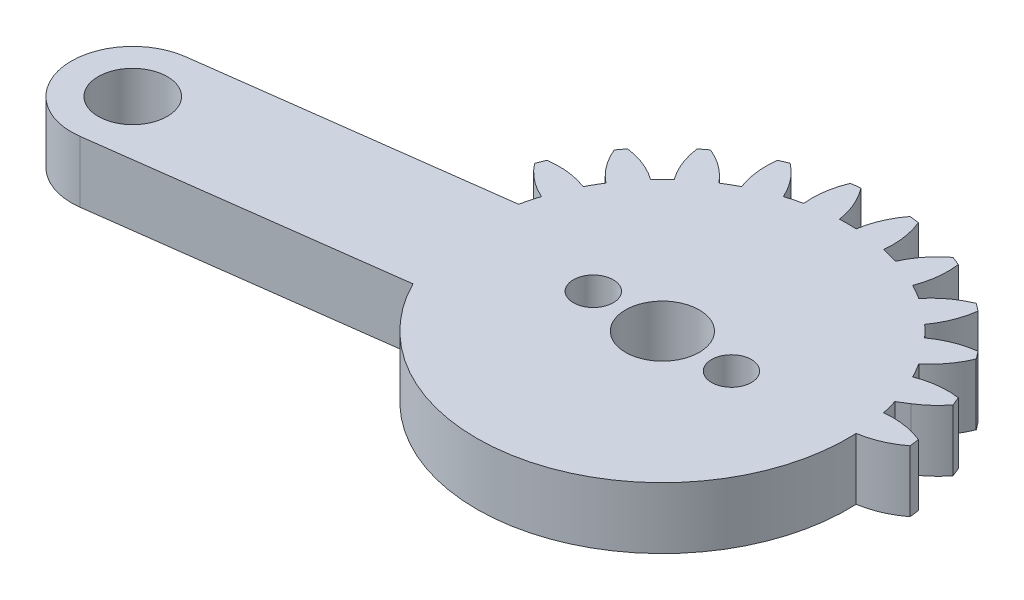
from build123d import *

# Parameters (mm, degrees)
SKETCH1_R           = 1.5
SKETCH1_R_2         = 2.25
BOSS_EXTRUDE1_DEPTH = 4
SKETCH3_R           = 2.25
BOSS_EXTRUDE2_DEPTH = 4
CUT_EXTRUDE1_DEPTH  = 4
CUT_EXTRUDE2_REACH  = 6
SKETCH5_R           = 1.3
SKETCH5_R_2         = 2.4


with BuildPart() as part:
    # Sketch1 → Boss-Extrude1 (new body)
    with BuildSketch(Plane(origin=(0, 0, 0), x_dir=(1, 0, 0), z_dir=(0, 1, 0))):
        with BuildLine():
            Line((20.643657446, 4), (2.081641936, 4))
            ThreePointArc((2.081641936, 4), (2.861028333, 4.588201733), (3.521749436, 5.30713988))
            ThreePointArc((3.521749436, 5.30713988), (3.405395609, 5.596745198), (3.282888305, 5.883801663))
            ThreePointArc((3.282888305, 5.883801663), (1.93527598, 5.894040025), (0.627094961, 5.57027124))
            ThreePointArc((0.627094961, 5.57027124), (0.366286148, 6.046375), (0.084372603, 6.510293938))
            ThreePointArc((0.084372603, 6.510293938), (1.018855105, 7.48132754), (1.683794586, 8.65351323))
            ThreePointArc((1.683794586, 8.65351323), (1.496450048, 8.903135899), (1.303821399, 9.148703928))
            ThreePointArc((1.303821399, 9.148703928), (-0.000522033, 8.809805691), (-1.180330337, 8.158486898))
            ThreePointArc((-1.180330337, 8.158486898), (-1.555477026, 8.550865528), (-1.947855656, 8.926012217))
            ThreePointArc((-1.947855656, 8.926012217), (-1.296536862, 10.105820521), (-0.957638625, 11.410163953))
            ThreePointArc((-0.957638625, 11.410163953), (-1.203206655, 11.602792602), (-1.452829324, 11.79013714))
            ThreePointArc((-1.452829324, 11.79013714), (-2.625015014, 11.125197659), (-3.596048616, 10.190715157))
            ThreePointArc((-3.596048616, 10.190715157), (-4.059967554, 10.472628702), (-4.536071314, 10.733437515))
            ThreePointArc((-4.536071314, 10.733437515), (-4.212302529, 12.041618533), (-4.222540891, 13.389230859))
            ThreePointArc((-4.222540891, 13.389230859), (-4.509597355, 13.511738163), (-4.799202674, 13.62809199))
            ThreePointArc((-4.799202674, 13.62809199), (-5.759348103, 12.682425791), (-6.455432668, 11.528463019))
            ThreePointArc((-6.455432668, 11.528463019), (-6.976508546, 11.680699536), (-7.503891752, 11.809396783))
            ThreePointArc((-7.503891752, 11.809396783), (-7.529737283, 13.156800143), (-7.888414517, 14.455843809))
            ThreePointArc((-7.888414517, 14.455843809), (-8.197396993, 14.499881098), (-8.507248835, 14.537314892))
            ThreePointArc((-8.507248835, 14.537314892), (-9.18992168, 13.375367565), (-9.563620196, 12.080565177))
            ThreePointArc((-9.563620196, 12.080565177), (-10.106342554, 12.09275), (-10.649064912, 12.080565177))
            ThreePointArc((-10.649064912, 12.080565177), (-11.022763428, 13.375367565), (-11.705436272, 14.537314892))
            ThreePointArc((-11.705436272, 14.537314892), (-12.015288115, 14.499881098), (-12.324270591, 14.455843809))
            ThreePointArc((-12.324270591, 14.455843809), (-12.682947825, 13.156800143), (-12.708793355, 11.809396783))
            ThreePointArc((-12.708793355, 11.809396783), (-13.236176561, 11.680699536), (-13.757252439, 11.528463019))
            ThreePointArc((-13.757252439, 11.528463019), (-14.453337005, 12.682425791), (-15.413482434, 13.62809199))
            ThreePointArc((-15.413482434, 13.62809199), (-15.703087752, 13.511738163), (-15.990144217, 13.389230859))
            ThreePointArc((-15.990144217, 13.389230859), (-16.000382579, 12.041618533), (-15.676613793, 10.733437515))
            ThreePointArc((-15.676613793, 10.733437515), (-16.152717554, 10.472628702), (-16.616636492, 10.190715157))
            ThreePointArc((-16.616636492, 10.190715157), (-17.587670094, 11.125197659), (-18.759855783, 11.79013714))
            ThreePointArc((-18.759855783, 11.79013714), (-19.009478453, 11.602792602), (-19.255046482, 11.410163953))
            ThreePointArc((-19.255046482, 11.410163953), (-18.916148245, 10.105820521), (-18.264829452, 8.926012217))
            ThreePointArc((-18.264829452, 8.926012217), (-18.657208082, 8.550865528), (-19.032354771, 8.158486898))
            ThreePointArc((-19.032354771, 8.158486898), (-20.212163074, 8.809805691), (-21.516506507, 9.148703928))
            ThreePointArc((-21.516506507, 9.148703928), (-21.709135156, 8.903135899), (-21.896479694, 8.65351323))
            ThreePointArc((-21.896479694, 8.65351323), (-21.231540213, 7.48132754), (-20.297057711, 6.510293938))
            ThreePointArc((-20.297057711, 6.510293938), (-20.578971255, 6.046375), (-20.839780068, 5.57027124))
            ThreePointArc((-20.839780068, 5.57027124), (-22.147961087, 5.894040025), (-23.495573413, 5.883801663))
            ThreePointArc((-23.495573413, 5.883801663), (-23.618080717, 5.596745198), (-23.734434544, 5.30713988))
            ThreePointArc((-23.734434544, 5.30713988), (-22.788768345, 4.346994451), (-21.634805572, 3.650909885))
            ThreePointArc((-21.634805572, 3.650909885), (-21.78704209, 3.129834008), (-21.915739337, 2.602450802))
            ThreePointArc((-21.915739337, 2.602450802), (-23.263142697, 2.576605271), (-24.562186363, 2.217928037))
            ThreePointArc((-24.562186363, 2.217928037), (-24.606223651, 1.908945561), (-24.643657446, 1.599093719))
            ThreePointArc((-24.643657446, 1.599093719), (-23.481710119, 0.916420874), (-22.186907731, 0.542722358))
            ThreePointArc((-22.186907731, 0.542722358), (-22.199092554, 0), (-22.186907731, -0.542722358))
            ThreePointArc((-22.186907731, -0.542722358), (-23.481710119, -0.916420874), (-24.643657446, -1.599093719))
            ThreePointArc((-24.643657446, -1.599093719), (-24.606223651, -1.908945561), (-24.562186363, -2.217928037))
            ThreePointArc((-24.562186363, -2.217928037), (-23.263142697, -2.576605271), (-21.915739337, -2.602450802))
            ThreePointArc((-21.915739337, -2.602450802), (-21.78704209, -3.129834008), (-21.634805572, -3.650909885))
            ThreePointArc((-21.634805572, -3.650909885), (-22.788768345, -4.346994451), (-23.734434544, -5.30713988))
            ThreePointArc((-23.734434544, -5.30713988), (-23.618080717, -5.596745198), (-23.495573413, -5.883801663))
            ThreePointArc((-23.495573413, -5.883801663), (-22.147961087, -5.894040025), (-20.839780068, -5.57027124))
            ThreePointArc((-20.839780068, -5.57027124), (-20.578971255, -6.046375), (-20.297057711, -6.510293938))
            ThreePointArc((-20.297057711, -6.510293938), (-21.231540213, -7.48132754), (-21.896479694, -8.65351323))
            ThreePointArc((-21.896479694, -8.65351323), (-21.709135156, -8.903135899), (-21.516506507, -9.148703928))
            ThreePointArc((-21.516506507, -9.148703928), (-20.212163074, -8.809805691), (-19.032354771, -8.158486898))
            ThreePointArc((-19.032354771, -8.158486898), (-18.657208082, -8.550865528), (-18.264829452, -8.926012217))
            ThreePointArc((-18.264829452, -8.926012217), (-18.916148245, -10.105820521), (-19.255046482, -11.410163953))
            ThreePointArc((-19.255046482, -11.410163953), (-19.009478453, -11.602792602), (-18.759855783, -11.79013714))
            ThreePointArc((-18.759855783, -11.79013714), (-17.587670094, -11.125197659), (-16.616636492, -10.190715157))
            ThreePointArc((-16.616636492, -10.190715157), (-16.152717554, -10.472628702), (-15.676613793, -10.733437515))
            ThreePointArc((-15.676613793, -10.733437515), (-16.000382579, -12.041618533), (-15.990144217, -13.389230859))
            ThreePointArc((-15.990144217, -13.389230859), (-15.703087752, -13.511738163), (-15.413482434, -13.62809199))
            ThreePointArc((-15.413482434, -13.62809199), (-14.453337005, -12.682425791), (-13.757252439, -11.528463019))
            ThreePointArc((-13.757252439, -11.528463019), (-13.236176561, -11.680699536), (-12.708793355, -11.809396783))
            ThreePointArc((-12.708793355, -11.809396783), (-12.682947825, -13.156800143), (-12.324270591, -14.455843809))
            ThreePointArc((-12.324270591, -14.455843809), (-12.015288115, -14.499881098), (-11.705436272, -14.537314892))
            ThreePointArc((-11.705436272, -14.537314892), (-11.022763428, -13.375367565), (-10.649064912, -12.080565177))
            ThreePointArc((-10.649064912, -12.080565177), (-10.106342554, -12.09275), (-9.563620196, -12.080565177))
            ThreePointArc((-9.563620196, -12.080565177), (-9.18992168, -13.375367565), (-8.507248835, -14.537314892))
            ThreePointArc((-8.507248835, -14.537314892), (-8.197396993, -14.499881098), (-7.888414517, -14.455843809))
            ThreePointArc((-7.888414517, -14.455843809), (-7.529737283, -13.156800143), (-7.503891752, -11.809396783))
            ThreePointArc((-7.503891752, -11.809396783), (-6.976508546, -11.680699536), (-6.455432668, -11.528463019))
            ThreePointArc((-6.455432668, -11.528463019), (-5.759348103, -12.682425791), (-4.799202674, -13.62809199))
            ThreePointArc((-4.799202674, -13.62809199), (-4.509597355, -13.511738163), (-4.222540891, -13.389230859))
            ThreePointArc((-4.222540891, -13.389230859), (-4.212302529, -12.041618533), (-4.536071314, -10.733437515))
            ThreePointArc((-4.536071314, -10.733437515), (-4.059967554, -10.472628702), (-3.596048616, -10.190715157))
            ThreePointArc((-3.596048616, -10.190715157), (-2.625015014, -11.125197659), (-1.452829324, -11.79013714))
            ThreePointArc((-1.452829324, -11.79013714), (-1.203206655, -11.602792602), (-0.957638625, -11.410163953))
            ThreePointArc((-0.957638625, -11.410163953), (-1.296536862, -10.105820521), (-1.947855656, -8.926012217))
            ThreePointArc((-1.947855656, -8.926012217), (-1.555477026, -8.550865528), (-1.180330337, -8.158486898))
            ThreePointArc((-1.180330337, -8.158486898), (-0.000522033, -8.809805691), (1.303821399, -9.148703928))
            ThreePointArc((1.303821399, -9.148703928), (1.496450048, -8.903135899), (1.683794586, -8.65351323))
            ThreePointArc((1.683794586, -8.65351323), (1.018855105, -7.48132754), (0.084372603, -6.510293938))
            ThreePointArc((0.084372603, -6.510293938), (0.366286148, -6.046375), (0.627094961, -5.57027124))
            ThreePointArc((0.627094961, -5.57027124), (1.93527598, -5.894040025), (3.282888305, -5.883801663))
            ThreePointArc((3.282888305, -5.883801663), (3.405395609, -5.596745198), (3.521749436, -5.30713988))
            ThreePointArc((3.521749436, -5.30713988), (2.861028333, -4.588201733), (2.081641936, -4))
            Line((2.081641936, -4), (20.643657446, -4))
            ThreePointArc((20.643657446, -4), (24.643657446, 0), (20.643657446, 4))
        make_face()
        with Locations((-10.106342554, 0)):
            Circle(SKETCH1_R, mode=Mode.SUBTRACT)
        with Locations((20.643657446, 0)):
            Circle(SKETCH1_R_2, mode=Mode.SUBTRACT)
    extrude(amount=BOSS_EXTRUDE1_DEPTH)

    # Sketch3 → Boss-Extrude2 (add)
    with BuildSketch(Plane(origin=(0, 4, 0), x_dir=(1, 0, 0), z_dir=(0, 1, 0))):
        with BuildLine():
            ThreePointArc((-9.584237785, -3.965779445), (-14.072121999, -0.522104769), (-10.628447323, 3.965779445))
            Line((-10.628447323, 3.965779445), (-41.11537681, -0.047900965))
            ThreePointArc((-41.11537681, -0.047900965), (-44.559051487, -4.53578518), (-40.071167272, -7.979459856))
            Line((-40.071167272, -7.979459856), (-9.584237785, -3.965779445))
        make_face()
        with Locations((-40.593272041, -4.013680411)):
            Circle(SKETCH3_R, mode=Mode.SUBTRACT)
    extrude(amount=-BOSS_EXTRUDE2_DEPTH)

    # Sketch4 → Cut-Extrude1 (cut)
    with BuildSketch(Plane(origin=(0, 4, 0), x_dir=(1, 0, 0), z_dir=(0, 1, 0))):
        with BuildLine():
            ThreePointArc((20.643657446, -4), (24.643657446, 0), (20.643657446, 4))
            Line((20.643657446, 4), (2.081641936, 4))
            Line((2.081641936, 4), (1.43808022, 3.600125745))
            ThreePointArc((1.43808022, 3.600125745), (1.581217534, 3.104116905), (1.70305423, 2.602450802))
            ThreePointArc((1.70305423, 2.602450802), (3.050457589, 2.576605271), (4.349501255, 2.217928037))
            ThreePointArc((4.349501255, 2.217928037), (4.393538544, 1.908945561), (4.430972339, 1.599093719))
            ThreePointArc((4.430972339, 1.599093719), (3.269025011, 0.916420874), (1.974222624, 0.542722358))
            ThreePointArc((1.974222624, 0.542722358), (1.70305423, -2.602450802), (0.627094961, -5.57027124))
            ThreePointArc((0.627094961, -5.57027124), (1.93527598, -5.894040025), (3.282888305, -5.883801663))
            ThreePointArc((3.282888305, -5.883801663), (3.405395609, -5.596745198), (3.521749436, -5.30713988))
            ThreePointArc((3.521749436, -5.30713988), (2.861028333, -4.588201733), (2.081641936, -4))
            Line((2.081641936, -4), (20.643657446, -4))
        make_face()
        with BuildLine():
            ThreePointArc((1.683794586, -8.65351323), (1.018855105, -7.48132754), (0.084372603, -6.510293938))
            ThreePointArc((0.084372603, -6.510293938), (-0.512518948, -7.361599771), (-1.180330337, -8.158486898))
            ThreePointArc((-1.180330337, -8.158486898), (-0.000522033, -8.809805691), (1.303821399, -9.148703928))
            ThreePointArc((1.303821399, -9.148703928), (1.496450048, -8.903135899), (1.683794586, -8.65351323))
        make_face()
        with BuildLine():
            ThreePointArc((-0.957638625, -11.410163953), (-1.296536862, -10.105820521), (-1.947855656, -8.926012217))
            ThreePointArc((-1.947855656, -8.926012217), (-2.744742783, -9.593823606), (-3.596048616, -10.190715157))
            ThreePointArc((-3.596048616, -10.190715157), (-2.625015014, -11.125197659), (-1.452829324, -11.79013714))
            ThreePointArc((-1.452829324, -11.79013714), (-1.203206655, -11.602792602), (-0.957638625, -11.410163953))
        make_face()
        with BuildLine():
            ThreePointArc((-4.222540891, -13.389230859), (-4.212302529, -12.041618533), (-4.536071314, -10.733437515))
            ThreePointArc((-4.536071314, -10.733437515), (-5.478647477, -11.172244217), (-6.455432668, -11.528463019))
            ThreePointArc((-6.455432668, -11.528463019), (-5.759348103, -12.682425791), (-4.799202674, -13.62809199))
            ThreePointArc((-4.799202674, -13.62809199), (-4.509597355, -13.511738163), (-4.222540891, -13.389230859))
        make_face()
        with BuildLine():
            ThreePointArc((-7.888414517, -14.455843809), (-7.529737283, -13.156800143), (-7.503891752, -11.809396783))
            ThreePointArc((-7.503891752, -11.809396783), (-8.527921943, -11.989294847), (-9.563620196, -12.080565177))
            ThreePointArc((-9.563620196, -12.080565177), (-9.18992168, -13.375367565), (-8.507248835, -14.537314892))
            ThreePointArc((-8.507248835, -14.537314892), (-8.197396993, -14.499881098), (-7.888414517, -14.455843809))
        make_face()
        with BuildLine():
            ThreePointArc((-11.705436272, -14.537314892), (-11.022763428, -13.375367565), (-10.649064912, -12.080565177))
            ThreePointArc((-10.649064912, -12.080565177), (-11.684763165, -11.989294847), (-12.708793355, -11.809396783))
            ThreePointArc((-12.708793355, -11.809396783), (-12.682947825, -13.156800143), (-12.324270591, -14.455843809))
            ThreePointArc((-12.324270591, -14.455843809), (-12.015288115, -14.499881098), (-11.705436272, -14.537314892))
        make_face()
        with BuildLine():
            ThreePointArc((-15.413482434, -13.62809199), (-14.453337005, -12.682425791), (-13.757252439, -11.528463019))
            ThreePointArc((-13.757252439, -11.528463019), (-14.734037631, -11.172244217), (-15.676613793, -10.733437515))
            ThreePointArc((-15.676613793, -10.733437515), (-16.000382579, -12.041618533), (-15.990144217, -13.389230859))
            ThreePointArc((-15.990144217, -13.389230859), (-15.703087752, -13.511738163), (-15.413482434, -13.62809199))
        make_face()
        with BuildLine():
            ThreePointArc((-18.759855783, -11.79013714), (-17.587670094, -11.125197659), (-16.616636492, -10.190715157))
            ThreePointArc((-16.616636492, -10.190715157), (-17.467942324, -9.593823606), (-18.264829452, -8.926012217))
            ThreePointArc((-18.264829452, -8.926012217), (-18.916148245, -10.105820521), (-19.255046482, -11.410163953))
            ThreePointArc((-19.255046482, -11.410163953), (-19.009478453, -11.602792602), (-18.759855783, -11.79013714))
        make_face()
        with BuildLine():
            ThreePointArc((-21.516506507, -9.148703928), (-20.212163074, -8.809805691), (-19.032354771, -8.158486898))
            ThreePointArc((-19.032354771, -8.158486898), (-19.70016616, -7.361599771), (-20.297057711, -6.510293938))
            ThreePointArc((-20.297057711, -6.510293938), (-21.231540213, -7.48132754), (-21.896479694, -8.65351323))
            ThreePointArc((-21.896479694, -8.65351323), (-21.709135156, -8.903135899), (-21.516506507, -9.148703928))
        make_face()
        with BuildLine():
            ThreePointArc((-21.942853375, 2.47620963), (-21.92946485, 2.539366405), (-21.915739337, 2.602450802))
            ThreePointArc((-21.915739337, 2.602450802), (-23.263142697, 2.576605271), (-24.562186363, 2.217928037))
            ThreePointArc((-24.562186363, 2.217928037), (-24.56889027, 2.173784387), (-24.575459377, 2.129620475))
            Line((-24.575459377, 2.129620475), (-21.942853375, 2.47620963))
        make_face()
        with BuildLine():
            ThreePointArc((-23.495573413, -5.883801663), (-22.147961087, -5.894040025), (-20.839780068, -5.57027124))
            ThreePointArc((-20.839780068, -5.57027124), (-20.869365339, -5.512888815), (-20.898643838, -5.455349261))
            Line((-20.898643838, -5.455349261), (-23.531249839, -5.801938416))
            ThreePointArc((-23.531249839, -5.801938416), (-23.513474108, -5.842897269), (-23.495573413, -5.883801663))
        make_face()
    extrude(amount=-CUT_EXTRUDE1_DEPTH, mode=Mode.SUBTRACT)

    # Sketch5 → Cut-Extrude2 (cut, up to next)
    with BuildSketch(Plane(origin=(0, 4, 0), x_dir=(1, 0, 0), z_dir=(0, 1, 0)), mode=Mode.PRIVATE) as cut_extrude2_sk1:
        with Locations((-14.606342554, 0)):
            Circle(SKETCH5_R)
    cut_extrude2_tool1 = extrude(cut_extrude2_sk1.sketch, amount=-CUT_EXTRUDE2_REACH, mode=Mode.PRIVATE) & part.part
    add(cut_extrude2_tool1.solids().sort_by_distance((-14.606343, 4, 0))[0], mode=Mode.SUBTRACT)
    # Sketch5 → Cut-Extrude2 (cut, up to next)
    with BuildSketch(Plane(origin=(0, 4, 0), x_dir=(1, 0, 0), z_dir=(0, 1, 0)), mode=Mode.PRIVATE) as cut_extrude2_sk2:
        with Locations((-5.606342554, 0)):
            Circle(SKETCH5_R)
    cut_extrude2_tool2 = extrude(cut_extrude2_sk2.sketch, amount=-CUT_EXTRUDE2_REACH, mode=Mode.PRIVATE) & part.part
    add(cut_extrude2_tool2.solids().sort_by_distance((-5.606343, 4, 0))[0], mode=Mode.SUBTRACT)
    # Sketch5 → Cut-Extrude2 (cut, up to next)
    with BuildSketch(Plane(origin=(0, 4, 0), x_dir=(1, 0, 0), z_dir=(0, 1, 0)), mode=Mode.PRIVATE) as cut_extrude2_sk3:
        with Locations((-10.106342554, 0)):
            Circle(SKETCH5_R_2)
    cut_extrude2_tool3 = extrude(cut_extrude2_sk3.sketch, amount=-CUT_EXTRUDE2_REACH, mode=Mode.PRIVATE) & part.part
    add(cut_extrude2_tool3.solids().sort_by_distance((-10.106343, 4, 0))[0], mode=Mode.SUBTRACT)


solid = part.part
